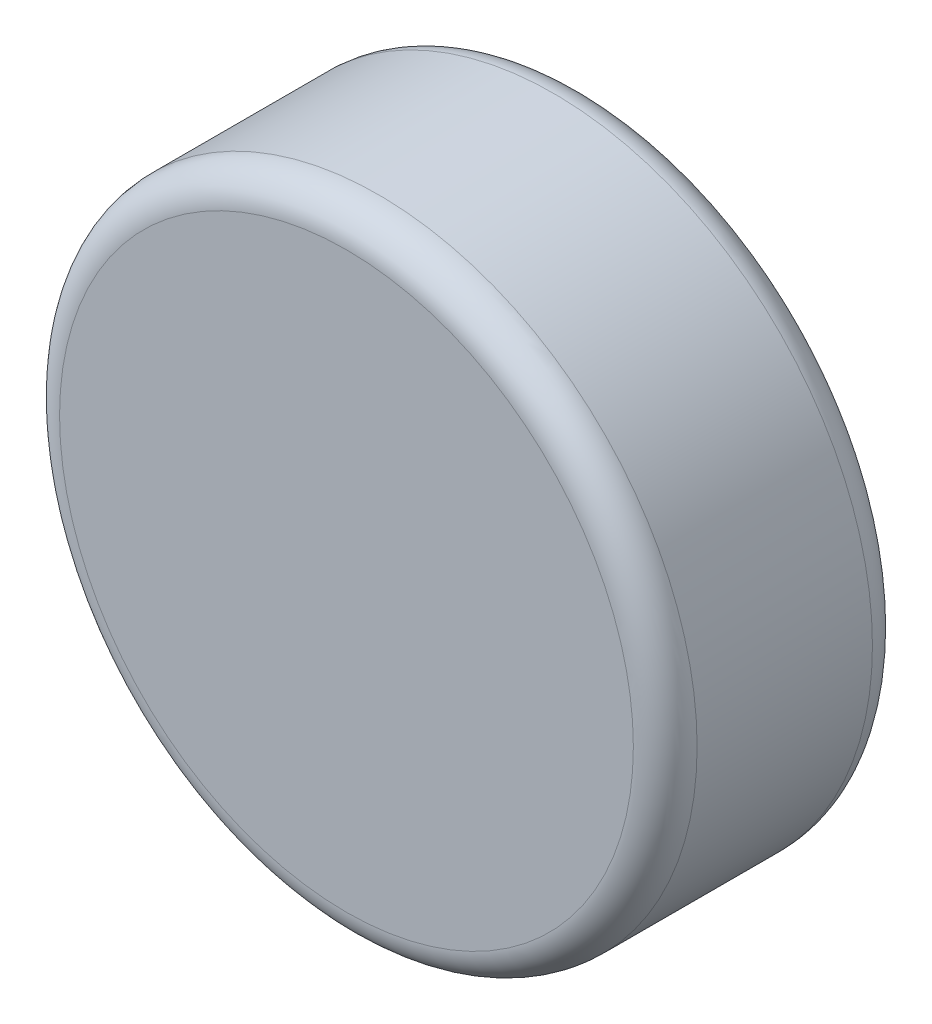
from build123d import *

# Parameters (mm, degrees)
SKETCH_1_R      = 40
EXTRUDE_1_DEPTH = 30
FILLET_1_R      = 4


with BuildPart() as part:
    # 草图1 → 凸台-拉伸1 (new body)
    with BuildSketch(Plane.XY):
        Circle(SKETCH_1_R)
    extrude(amount=EXTRUDE_1_DEPTH)

    # 圆角1
    fillet_1_edges = [part.edges().sort_by_distance(p)[0] for p in [
        (-40, 0, 0),
        (-40, 0, 30),
    ]]
    fillet(fillet_1_edges, radius=FILLET_1_R)


solid = part.part
